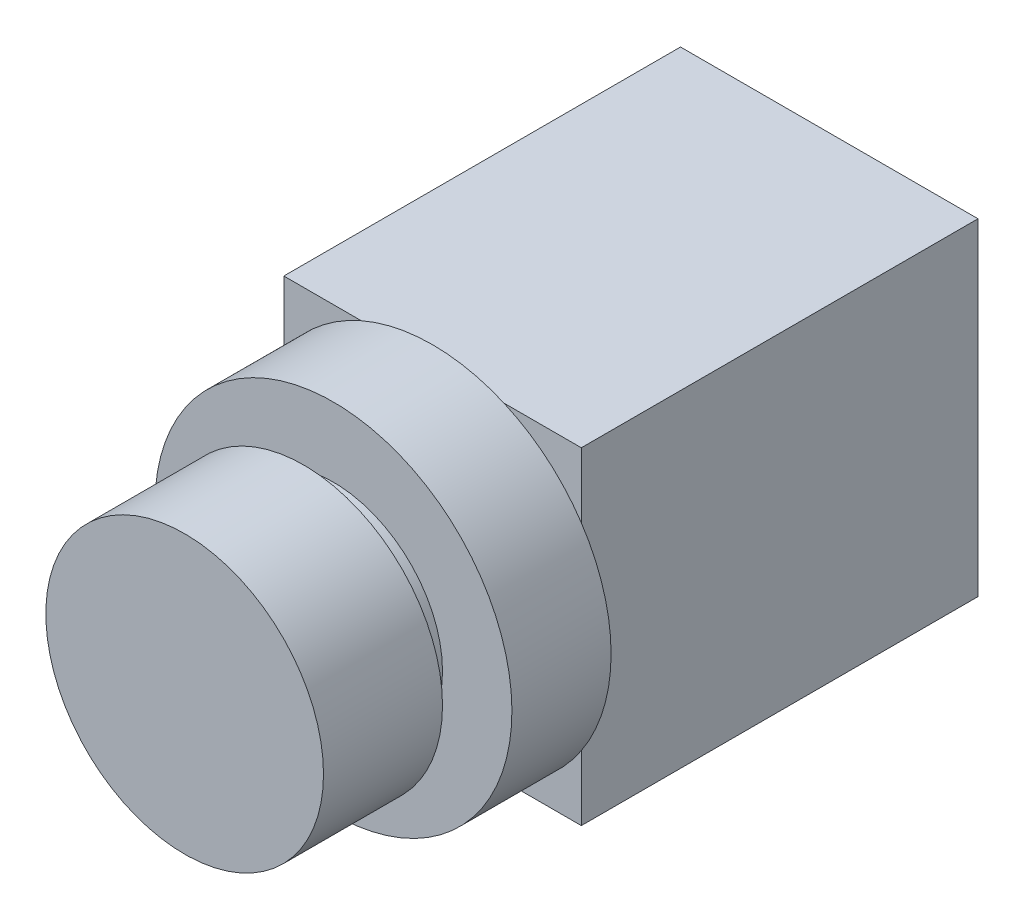
from build123d import *

# Parameters (mm, degrees)
SKETCH_1_R      = 14
EXTRUDE_1_DEPTH = 12
SKETCH_2_R      = 11
EXTRUDE_2_DEPTH = 3
SKETCH_3_R      = 18
EXTRUDE_3_DEPTH = 10
SKETCH_4_W      = 30
SKETCH_4_H      = 33
EXTRUDE_4_DEPTH = 40


with BuildPart() as part:
    # 草图1 → 凸台-拉伸1 (new body)
    with BuildSketch(Plane.XY):
        Circle(SKETCH_1_R)
    extrude(amount=EXTRUDE_1_DEPTH)

    # 草图2 → 凸台-拉伸2 (add)
    with BuildSketch(Plane(origin=(0, 0, 0), x_dir=(-1, 0, 0), z_dir=(0, 0, -1))):
        Circle(SKETCH_2_R)
    extrude(amount=EXTRUDE_2_DEPTH)

    # 草图3 → 凸台-拉伸3 (add)
    with BuildSketch(Plane(origin=(0, 0, -3), x_dir=(-1, 0, 0), z_dir=(0, 0, -1))):
        Circle(SKETCH_3_R)
    extrude(amount=EXTRUDE_3_DEPTH)

    # 草图4 → 凸台-拉伸4 (add)
    with BuildSketch(Plane(origin=(0, 0, -13), x_dir=(-1, 0, 0), z_dir=(0, 0, -1))):
        Rectangle(SKETCH_4_W, SKETCH_4_H)
    extrude(amount=EXTRUDE_4_DEPTH)


solid = part.part
